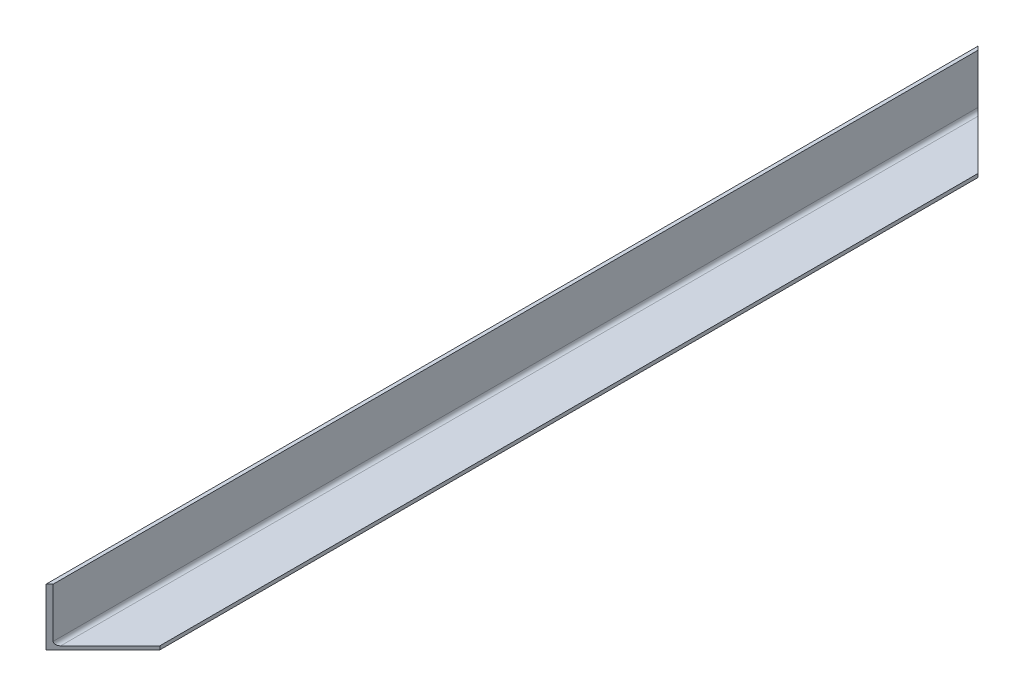
from build123d import *

# Parameters (mm, degrees)
BOSS_EXTRUDE1_DEPTH      = 415.925
BOSS_EXTRUDE1_DEPTH_BACK = 415.925
CUT_EXTRUDE2_DEPTH       = 48.625
CUT_EXTRUDE2_DEPTH_BACK  = 4.175


with BuildPart() as part:
    # Sketch4 → Boss-Extrude1 (new body, two sides)
    with BuildSketch(Plane.XY) as boss_extrude1_sk:
        with BuildLine():
            Line((-22.225, -18.838333333), (-22.225, 25.4))
            Line((-22.225, 25.4), (-25.4, 25.4))
            Line((-25.4, 25.4), (-25.4, -25.4))
            Line((-25.4, -25.4), (25.4, -25.4))
            Line((25.4, -25.4), (25.4, -22.225))
            Line((25.4, -22.225), (-18.838333333, -22.225))
            ThreePointArc((-18.838333333, -22.225), (-21.233068299, -21.233068299), (-22.225, -18.838333333))
        make_face()
    extrude(amount=BOSS_EXTRUDE1_DEPTH)
    extrude(boss_extrude1_sk.sketch, amount=-BOSS_EXTRUDE1_DEPTH_BACK)

    # Sketch5 → Cut-Extrude2 (cut, two sides)
    with BuildSketch(Plane(origin=(0, -22.225, 0), x_dir=(1, 0, 0), z_dir=(0, 1, 0))) as cut_extrude2_sk:
        Polygon((-25.4, 415.925), (25.4, 365.125), (25.4, 415.925), align=None)
        Polygon((25.4, -415.925), (25.4, -365.125), (-25.4, -415.925), align=None)
    extrude(amount=CUT_EXTRUDE2_DEPTH, mode=Mode.SUBTRACT)
    extrude(cut_extrude2_sk.sketch, amount=-CUT_EXTRUDE2_DEPTH_BACK, mode=Mode.SUBTRACT)


solid = part.part
